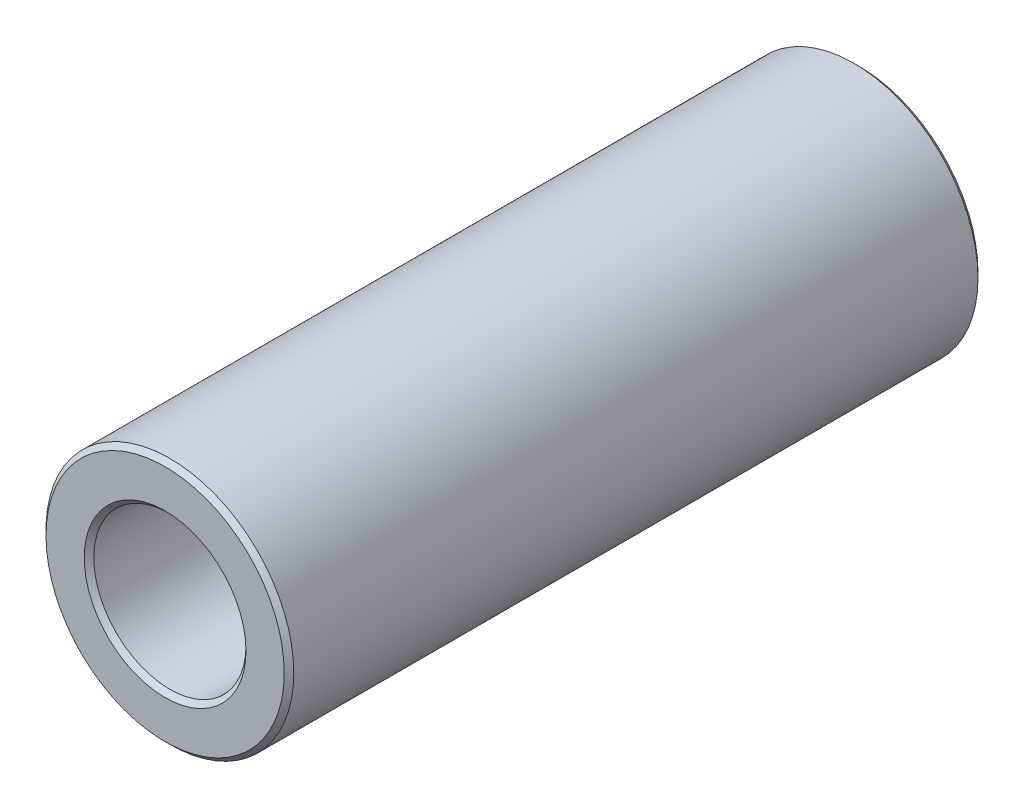
from build123d import *

# Parameters (mm, degrees)
BOSS_EXTRUDE1_DEPTH      = 11.1125
BOSS_EXTRUDE1_DEPTH_BACK = 11.1125
SKETCH3_R                = 3.96875
SKETCH3_R_2              = 2.4384
CHAMFER1_SIZE            = 0.153035


with BuildPart() as part:
    # Sketch3 → Boss-Extrude1 (new, two sides: drawn at the far end of the back side and taken through both)
    with BuildSketch(Plane.XY.offset(-BOSS_EXTRUDE1_DEPTH_BACK)):
        Circle(SKETCH3_R)
        Circle(SKETCH3_R_2, mode=Mode.SUBTRACT)
    extrude(amount=BOSS_EXTRUDE1_DEPTH + BOSS_EXTRUDE1_DEPTH_BACK)

    # Chamfer1
    chamfer1_edges = [part.edges().sort_by_distance(p)[0] for p in [
        (-3.96875, 0, -11.1125),
        (-2.4384, 0, -11.1125),
        (-3.96875, 0, 11.1125),
        (-2.4384, 0, 11.1125),
    ]]
    chamfer(chamfer1_edges, length=CHAMFER1_SIZE)


solid = part.part
